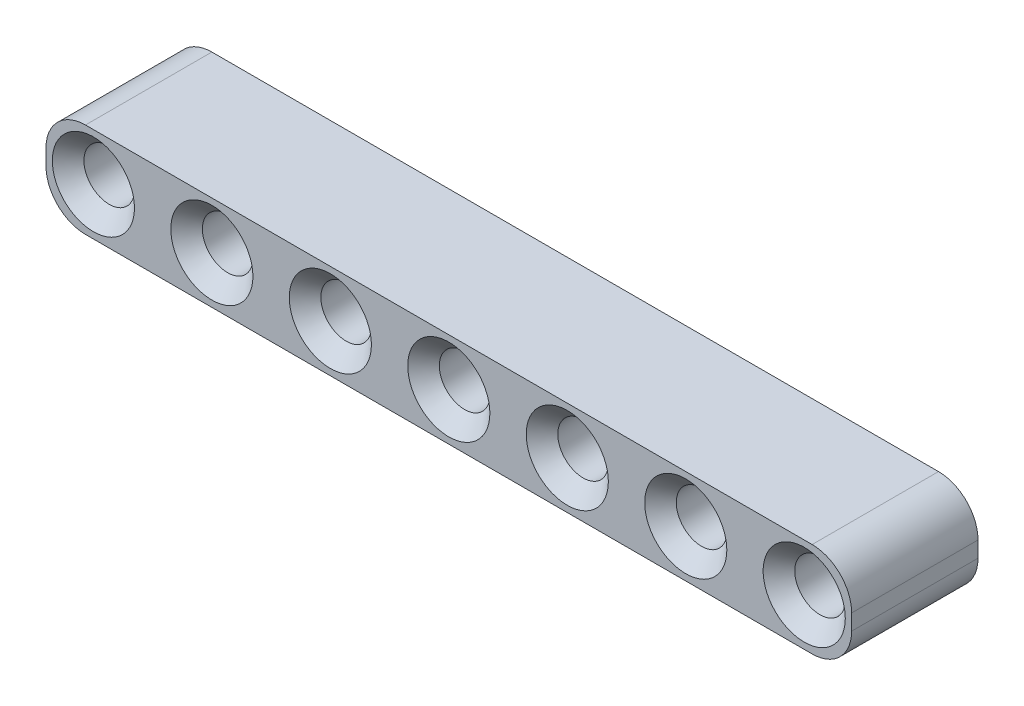
from build123d import *

# Parameters (mm, degrees)
SKETCH1_R           = 1.6
BOSS_EXTRUDE1_DEPTH = 8
CHAMFER1_SIZE       = 1


with BuildPart() as part:
    # Sketch1 → Boss-Extrude1 (new body)
    with BuildSketch(Plane.XY):
        with BuildLine():
            Line((-0.5, 3), (45.5, 3))
            ThreePointArc((45.5, 3), (47.267766953, 2.267766953), (48, 0.5))
            Line((48, 0.5), (48, -0.5))
            ThreePointArc((48, -0.5), (47.267766953, -2.267766953), (45.5, -3))
            Line((45.5, -3), (-0.5, -3))
            ThreePointArc((-0.5, -3), (-2.267766953, -2.267766953), (-3, -0.5))
            Line((-3, -0.5), (-3, 0.5))
            ThreePointArc((-3, 0.5), (-2.267766953, 2.267766953), (-0.5, 3))
        make_face()
        Circle(SKETCH1_R, mode=Mode.SUBTRACT)
        with Locations((7.5, 0)):
            Circle(SKETCH1_R, mode=Mode.SUBTRACT)
        with Locations((15, 0)):
            Circle(SKETCH1_R, mode=Mode.SUBTRACT)
        with Locations((22.5, 0)):
            Circle(SKETCH1_R, mode=Mode.SUBTRACT)
        with Locations((30, 0)):
            Circle(SKETCH1_R, mode=Mode.SUBTRACT)
        with Locations((37.5, 0)):
            Circle(SKETCH1_R, mode=Mode.SUBTRACT)
        with Locations((45, 0)):
            Circle(SKETCH1_R, mode=Mode.SUBTRACT)
    extrude(amount=BOSS_EXTRUDE1_DEPTH)

    # Chamfer1
    chamfer1_edges = [part.edges().sort_by_distance(p)[0] for p in [
        (-1.6, 0, 0),
        (-1.6, 0, 8),
        (5.9, 0, 0),
        (5.9, 0, 8),
        (13.4, 0, 0),
        (13.4, 0, 8),
        (20.9, 0, 0),
        (20.9, 0, 8),
        (28.4, 0, 0),
        (28.4, 0, 8),
        (35.9, 0, 0),
        (35.9, 0, 8),
        (43.4, 0, 0),
        (43.4, 0, 8),
    ]]
    chamfer(chamfer1_edges, length=CHAMFER1_SIZE)


solid = part.part
